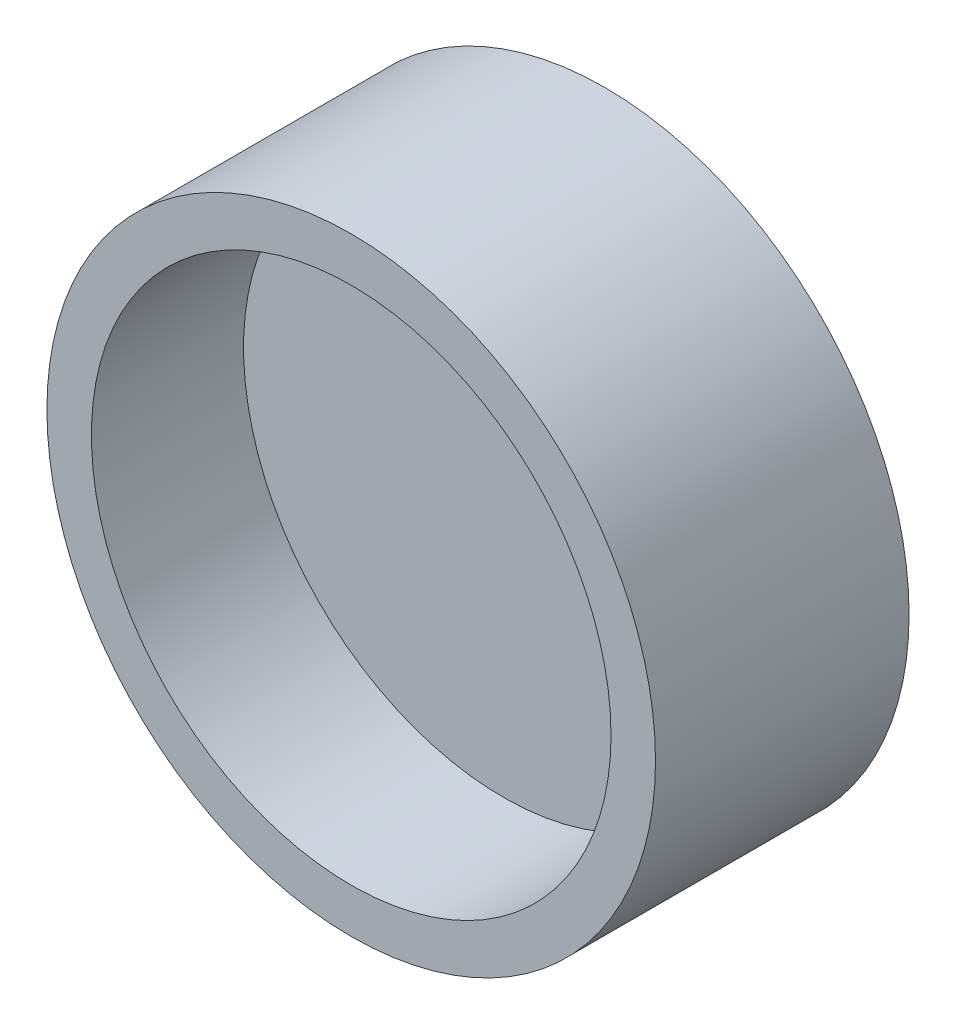
from build123d import *

# Parameters (mm, degrees)
SKETCH1_R           = 25.613906161
BOSS_EXTRUDE1_DEPTH = 10
SKETCH1_3_R         = 30
SKETCH1_3_R_2       = 25.613906161
BOSS_EXTRUDE2_DEPTH = 25


with BuildPart() as part:
    # Sketch1 → Boss-Extrude1 (new body)
    with BuildSketch(Plane.XY):
        Circle(SKETCH1_R)
    extrude(amount=BOSS_EXTRUDE1_DEPTH)

    # Sketch1_3 → Boss-Extrude2 (add)
    with BuildSketch(Plane.XY):
        Circle(SKETCH1_3_R)
        Circle(SKETCH1_3_R_2, mode=Mode.SUBTRACT)
    extrude(amount=BOSS_EXTRUDE2_DEPTH)


solid = part.part
